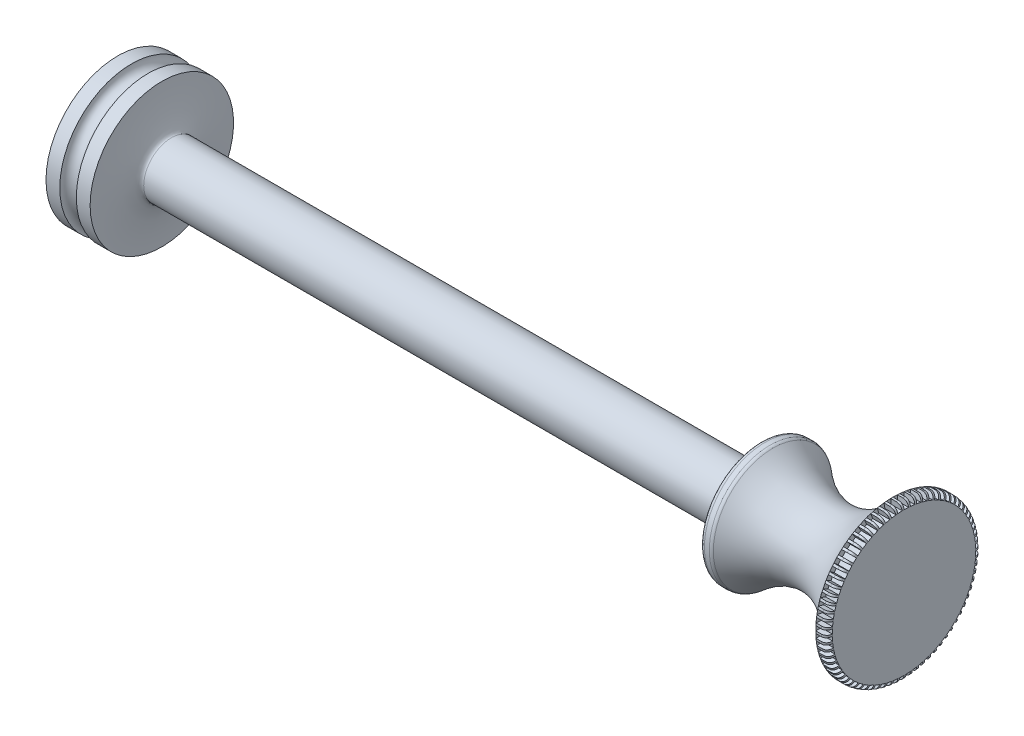
from build123d import *

# Parameters (mm, degrees)
ZAOBLIT2_R               = 0.5
ZAOBLIT3_R               = 0.4
SKICA2_W                 = 2
SKICA2_H                 = 0.4
ODEBRAT_VYSUNUT_M1_DEPTH = 0.5
KRUHOV_POLE1_COUNT       = 72


with BuildPart() as part:
    # Skica1 → Rotovat1 (revolve)
    with BuildSketch(Plane(origin=(0, 0, 0), x_dir=(1, 0, 0), z_dir=(0, 1, 0))):
        with BuildLine():
            Line((0, 0), (-8.419685315, 0))
            add(Edge.make_bspline(
                [(-9.279110559, 4), (-9.155778571, -0.024179303), (-8.419685315, 0)],
                knots=[4.700372114, 4.700372114, 4.700372114, 6.283185307, 6.283185307, 6.283185307], degree=2, weights=[1, 0.702845439, 1]))
            Line((-9.279110559, 4), (-10.529110559, 4))
            ThreePointArc((-10.529110559, 4), (-11.279110559, 3.25), (-12.029110559, 4))
            Line((-12.029110559, 4), (-13.279110559, 4))
            add(Edge.make_bspline(
                [(-14.138535803, 0), (-13.402442547, -0.024179303), (-13.279110559, 4)],
                knots=[0, 0, 0, 1.582813193, 1.582813193, 1.582813193], degree=2, weights=[1, 0.702845439, 1]))
            Line((-14.138535803, 0), (-14.138535803, -2.5))
            Line((-14.138535803, -2.5), (25.137573104, -2.5))
            Line((25.137573104, -2.5), (58, -2.5))
            Line((58, -2.5), (58, 4.5))
            Line((58, 4.5), (57, 4.5))
            add(Edge.make_bspline(
                [(46, 3), (51.825824642, -2.277734238), (57, 4.5)],
                knots=[0, 0, 0, 1, 1, 1], degree=2))
            Line((46, 3), (45, 3))
            Line((45, 3), (45, 0))
            Line((45, 0), (0, 0))
        make_face()
    revolve(axis=Axis((-14.138535803, 0, 2.5), (1, 0, 0)))

    # Zaoblit2
    zaoblit2_edges = [part.edges().sort_by_distance(p)[0] for p in [
        (58, 0, 9.5),
    ]]
    fillet(zaoblit2_edges, radius=ZAOBLIT2_R)

    # Zaoblit3
    zaoblit3_edges = [part.edges().sort_by_distance(p)[0] for p in [
        (45, 0, 8),
        (46, 0, 8),
    ]]
    fillet(zaoblit3_edges, radius=ZAOBLIT3_R)

    # Skica2 → Odebrat vysunutím1 (cut)
    with BuildSketch(Plane.XY.offset(9.5)):
        with Locations((58, 0.2)):
            Rectangle(SKICA2_W, SKICA2_H)
    odebrat_vysunut_m1 = extrude(amount=-ODEBRAT_VYSUNUT_M1_DEPTH, mode=Mode.SUBTRACT)

    # Kruhové pole1: Odebrat vysunutím1 ×72 about axis
    kruhov_pole1_axis = Axis((45, 0, 2.5), (-1, 0, 0))
    for i in range(1, KRUHOV_POLE1_COUNT):
        add(odebrat_vysunut_m1.rotate(kruhov_pole1_axis, i * 360 / KRUHOV_POLE1_COUNT), mode=Mode.SUBTRACT)


solid = part.part
